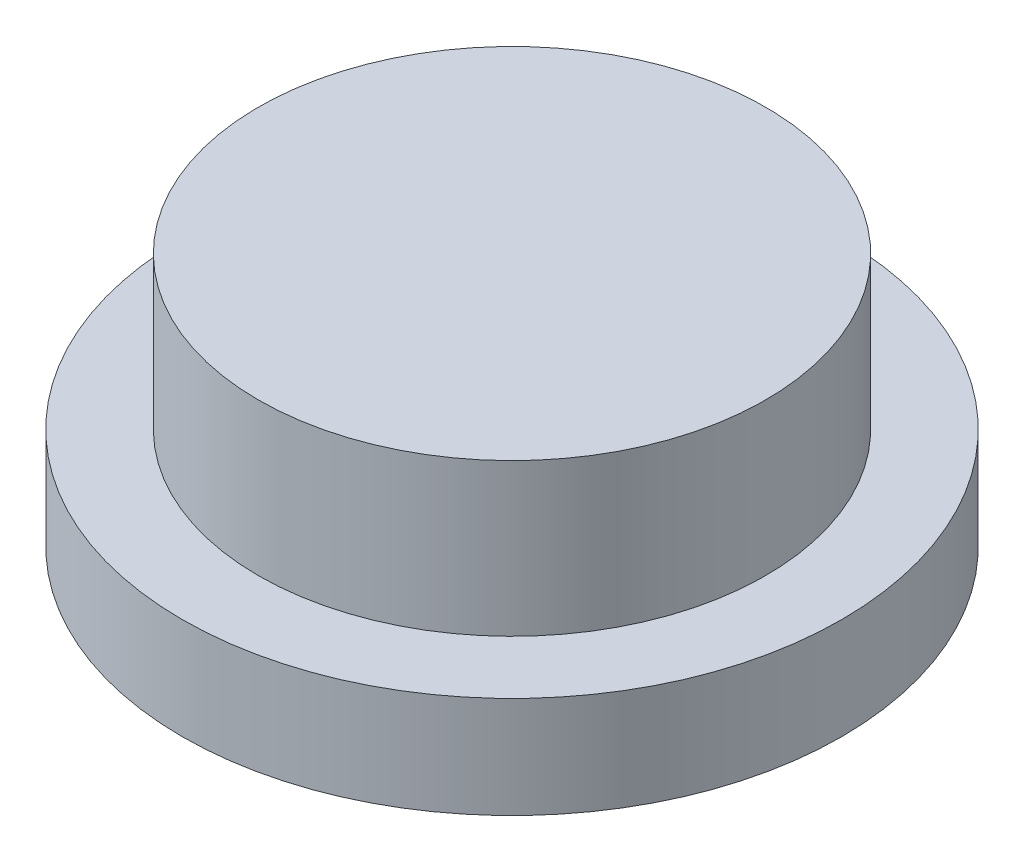
from build123d import *


with BuildPart() as part:
    # Эскиз1 → Повернуть1 (revolve)
    with BuildSketch(Plane(origin=(0, 0, 0), x_dir=(0, 0, -1), z_dir=(1, 0, 0))):
        Polygon((0, 10), (10, 10), (10, 4), (13, 4), (13, 0), (0, 0), align=None)
    revolve(axis=Axis((0, 57.539261388, 0), (0, -1, 0)))


solid = part.part
